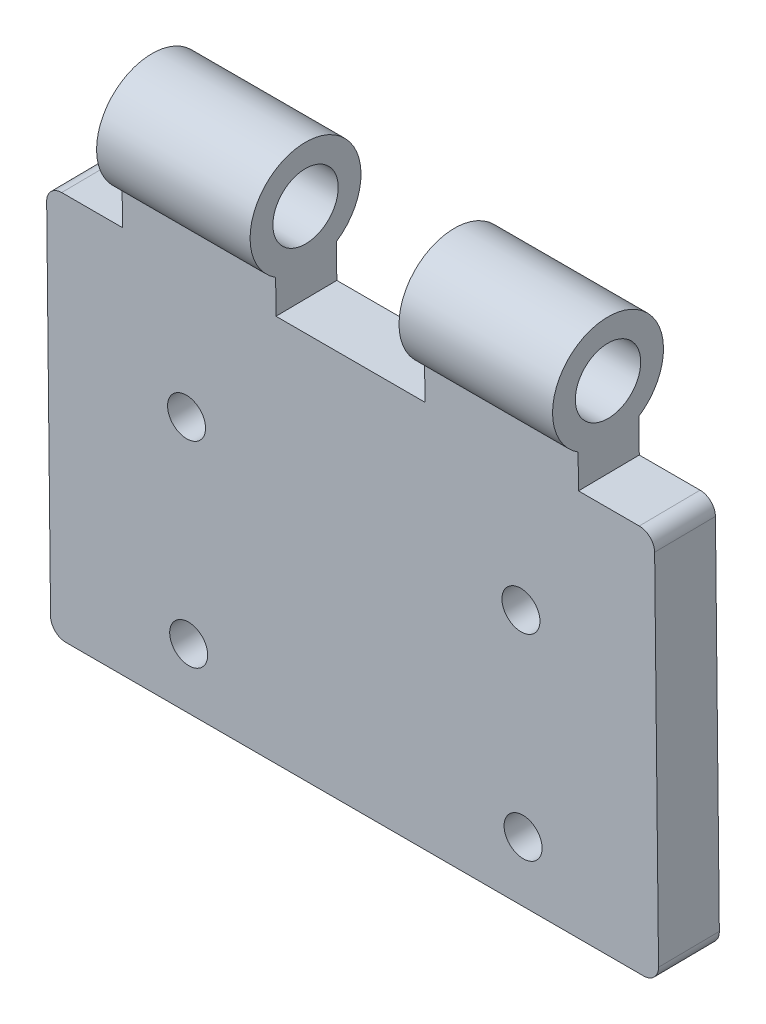
from build123d import *

# Parameters (mm, degrees)
SKETCH_1_R          = 2.15
EXTRUDE_1_DEPTH     = 40
SKETCH_3_R          = 1.25
CUT_EXTRUDE_2_DEPTH = 4.000232305
SKETCH_2_W          = 5
SKETCH_2_H          = 10
SKETCH_2_W_2        = 9.8
CUT_EXTRUDE_3_DEPTH = 11
FILLET_1_R          = 1


with BuildPart() as part:
    # 草图1 → 凸台-拉伸1 (new body)
    with BuildSketch(Plane(origin=(0, 0, 0), x_dir=(0, 0, -1), z_dir=(1, 0, 0))):
        with BuildLine():
            Line((-1.96709588, -3.074578638), (-1.665324422, -31.074578638))
            Line((-1.665324422, -31.074578638), (2.334675578, -31.031468429))
            Line((2.334675578, -31.031468429), (2.03290412, -3.031468429))
            ThreePointArc((2.03290412, -3.031468429), (-0.039335781, 3.649788034), (-1.96709588, -3.074578638))
        make_face()
        Circle(SKETCH_1_R, mode=Mode.SUBTRACT)
    extrude(amount=EXTRUDE_1_DEPTH)

    # 草图3 → 切除-拉伸2 (cut)
    with BuildSketch(Plane(origin=(0, 0.021555104, -2), x_dir=(-1, 0, 0), z_dir=(0, 0.010776926175386807, -0.9999419272448828))):
        with Locations(Location((-31.120103863, -27.054826973, 0), (0, 0, 90))):
            Circle(SKETCH_3_R)
        with Locations(Location((-31.120103863, -14.054826973, 0), (0, 0, 90))):
            Circle(SKETCH_3_R)
        with Locations(Location((-9.120103863, -27.054826973, 0), (0, 0, 90))):
            Circle(SKETCH_3_R)
        with Locations(Location((-9.120103863, -14.054826973, 0), (0, 0, 90))):
            Circle(SKETCH_3_R)
    extrude(amount=-CUT_EXTRUDE_2_DEPTH, mode=Mode.SUBTRACT)

    # 草图2 → 切除-拉伸3 (cut, symmetric)
    with BuildSketch(Plane(origin=(0, -0.021555104, 2), x_dir=(1, 0, 0), z_dir=(0, -0.010776926175386815, 0.9999419272448828))):
        with Locations((2.5, -0.278741266)):
            Rectangle(SKETCH_2_W, SKETCH_2_H)
        with Locations((20, -0.278741266)):
            Rectangle(SKETCH_2_W_2, SKETCH_2_H)
        with Locations((37.5, -0.278741266)):
            Rectangle(SKETCH_2_W, SKETCH_2_H)
    extrude(amount=CUT_EXTRUDE_3_DEPTH, both=True, mode=Mode.SUBTRACT)

    # 圆角1
    fillet_1_edges = [part.edges().sort_by_distance(p)[0] for p in [
        (40, -31.053023534, -0.334675578),
        (0, -5.278434715, -0.056888605),
        (0, -31.053023534, -0.334675578),
        (40, -5.278434715, -0.056888605),
    ]]
    fillet(fillet_1_edges, radius=FILLET_1_R)


solid = part.part
